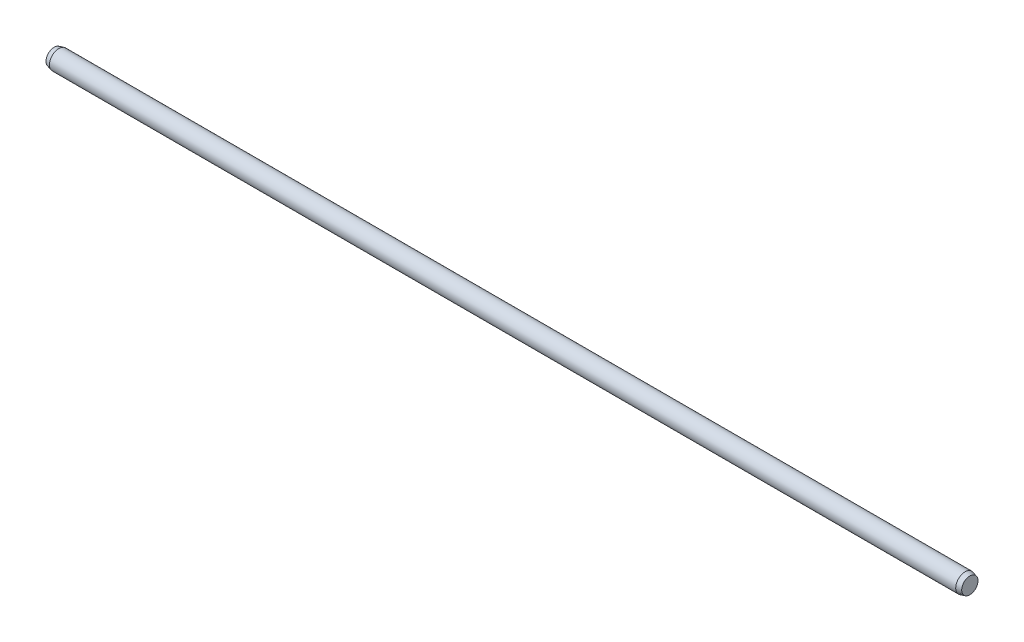
from build123d import *

# Parameters (mm, degrees)
SKETCH1_R           = 4
BOSS_EXTRUDE1_DEPTH = 194.5
CHAMFER3_SIZE       = 2
CHAMFER3_SIZE2      = 0.535898385
CHAMFER4_SIZE       = 2
CHAMFER4_SIZE2      = 0.535898385


with BuildPart() as part:
    # Sketch1 → Boss-Extrude1 (new body, symmetric)
    with BuildSketch(Plane(origin=(0, 0, 0), x_dir=(0, 0, -1), z_dir=(1, 0, 0))):
        Circle(SKETCH1_R)
    extrude(amount=BOSS_EXTRUDE1_DEPTH, both=True)

    # Chamfer3
    chamfer3_edges = [part.edges().sort_by_distance(p)[0] for p in [
        (194.5, 0, 4),
    ]]
    chamfer3_side = [part.faces().sort_by_distance(p)[0] for p in [
        (0, 0, 4),
    ]]
    chamfer(chamfer3_edges, length=CHAMFER3_SIZE, length2=CHAMFER3_SIZE2, reference=chamfer3_side[0])

    # Chamfer4
    chamfer4_edges = [part.edges().sort_by_distance(p)[0] for p in [
        (-194.5, 0, 4),
    ]]
    chamfer4_side = [part.faces().sort_by_distance(p)[0] for p in [
        (-1, 0, 4),
    ]]
    chamfer(chamfer4_edges, length=CHAMFER4_SIZE, length2=CHAMFER4_SIZE2, reference=chamfer4_side[0])


solid = part.part
